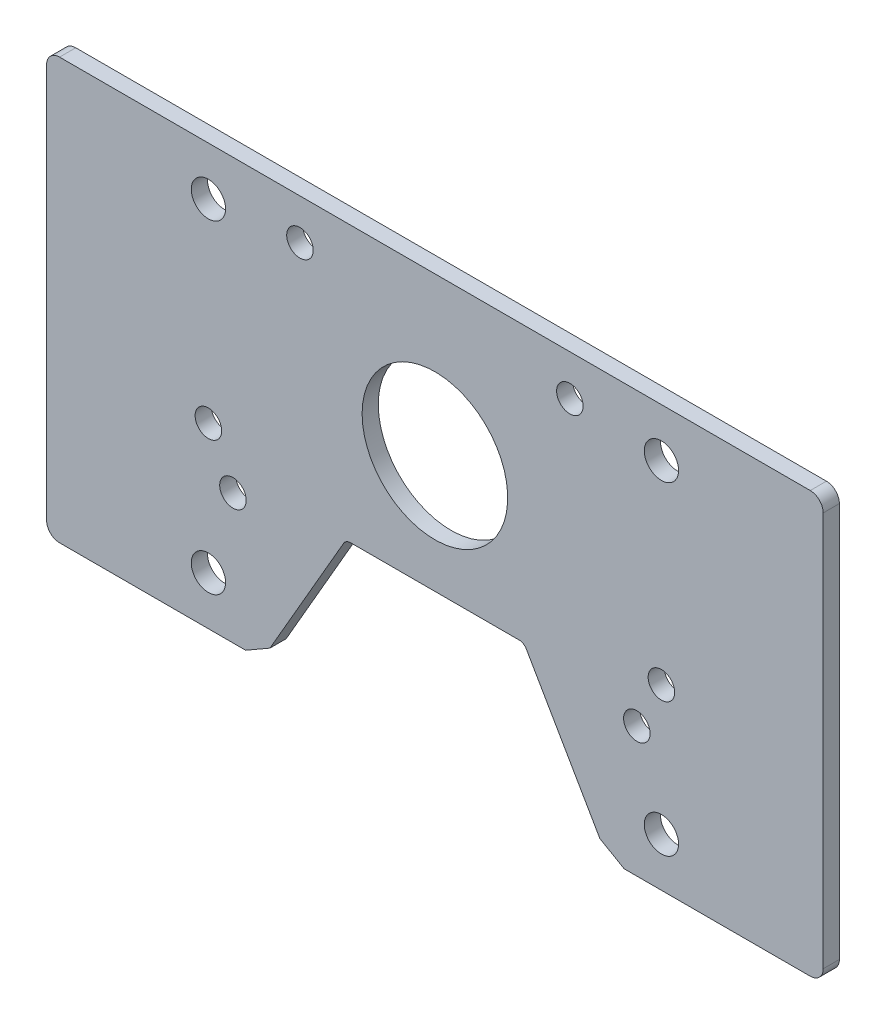
from build123d import *

# Parameters (mm, degrees)
SKETCH1_R           = 2.6035
SKETCH1_R_2         = 3.3655
SKETCH1_R_3         = 14.2875
BOSS_EXTRUDE1_DEPTH = 3.175
SKETCH2_W           = 25.4
SKETCH2_H           = 82.55
BOSS_EXTRUDE2_DEPTH = 3.175
FILLET1_R           = 2.54


with BuildPart() as part:
    # Sketch1 → Boss-Extrude1 (new body)
    with BuildSketch(Plane.XY.offset(3.175)):
        with BuildLine():
            Line((53.975, -25.4), (53.975, 50.8))
            Line((53.975, 50.8), (50.8, 53.975))
            Line((50.8, 53.975), (-50.8, 53.975))
            Line((-50.8, 53.975), (-53.975, 50.8))
            Line((-53.975, 50.8), (-53.975, -25.4))
            Line((-53.975, -25.4), (-50.8, -28.575))
            Line((-50.8, -28.575), (-37.135283942, -28.575))
            Line((-37.135283942, -28.575), (-32.372783942, -25.825369343))
            Line((-32.372783942, -25.825369343), (-17.920771776, -0.79375))
            ThreePointArc((-17.920771776, -0.79375), (-17.339706448, -0.212684671), (-16.545956448, 0))
            Line((-16.545956448, 0), (16.545956448, 0))
            ThreePointArc((16.545956448, 0), (17.339706448, -0.212684671), (17.920771776, -0.79375))
            Line((17.920771776, -0.79375), (32.372783942, -25.825369343))
            Line((32.372783942, -25.825369343), (37.135283942, -28.575))
            Line((37.135283942, -28.575), (50.8, -28.575))
            Line((50.8, -28.575), (53.975, -25.4))
        make_face()
        with Locations((44.45, 6.35)):
            Circle(SKETCH1_R, mode=Mode.SUBTRACT)
        with Locations((26.484101205, 46.005749811)):
            Circle(SKETCH1_R, mode=Mode.SUBTRACT)
        with Locations((-39.632108696, -3.063282164)):
            Circle(SKETCH1_R, mode=Mode.SUBTRACT)
        with Locations((44.45, -19.05)):
            Circle(SKETCH1_R_2, mode=Mode.SUBTRACT)
        with Locations((44.45, 44.45)):
            Circle(SKETCH1_R_2, mode=Mode.SUBTRACT)
        with Locations((0, 23.058733918)):
            Circle(SKETCH1_R_3, mode=Mode.SUBTRACT)
        with Locations((-44.45, 44.45)):
            Circle(SKETCH1_R_2, mode=Mode.SUBTRACT)
        with Locations((-44.45, -19.05)):
            Circle(SKETCH1_R_2, mode=Mode.SUBTRACT)
        with Locations((-44.45, 6.35)):
            Circle(SKETCH1_R, mode=Mode.SUBTRACT)
        with Locations((-26.484101205, 46.005749811)):
            Circle(SKETCH1_R, mode=Mode.SUBTRACT)
        with Locations((39.632108696, -3.063282164)):
            Circle(SKETCH1_R, mode=Mode.SUBTRACT)
    extrude(amount=-BOSS_EXTRUDE1_DEPTH)

    # Sketch2 → Boss-Extrude2 (add, through all)
    with BuildSketch(Plane.XY.offset(3.175)):
        with Locations((-63.5, 12.7)):
            Rectangle(SKETCH2_W, SKETCH2_H)
        with Locations((63.5, 12.7)):
            Rectangle(SKETCH2_W, SKETCH2_H)
    extrude(amount=-BOSS_EXTRUDE2_DEPTH)

    # Fillet1
    fillet1_edges = [part.edges().sort_by_distance(p)[0] for p in [
        (76.2, -28.575, 1.5875),
        (76.2, 53.975, 1.5875),
        (-76.2, -28.575, 1.5875),
        (-76.2, 53.975, 1.5875),
    ]]
    fillet(fillet1_edges, radius=FILLET1_R)


solid = part.part
